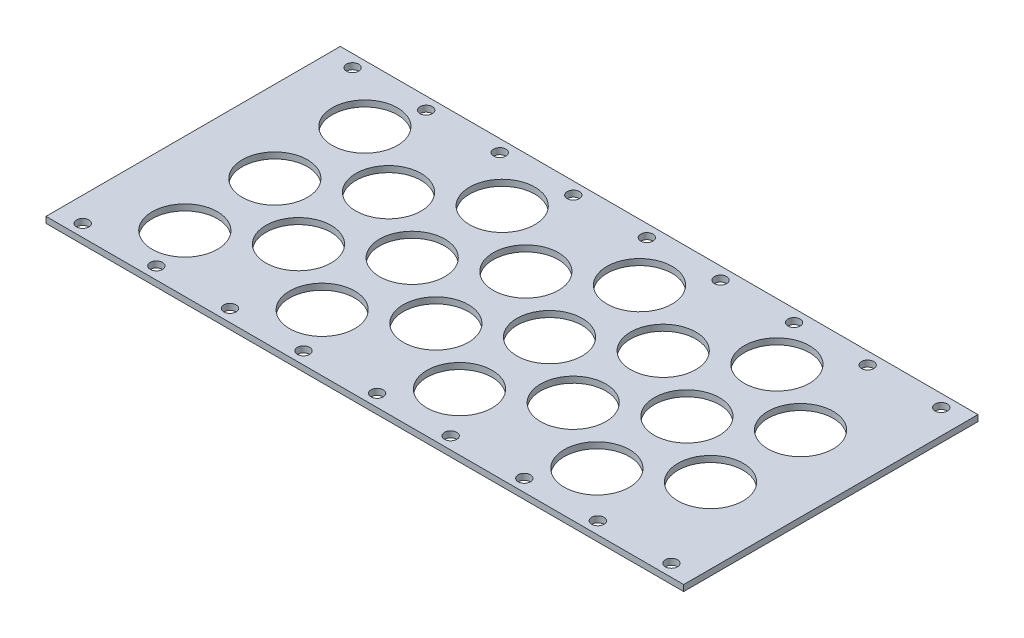
from build123d import *

# Parameters (mm, degrees)
SKETCH1_W           = 330.2
SKETCH1_H           = 152.4
BOSS_EXTRUDE1_DEPTH = 3.175
SKETCH2_R           = 3.175
CUT_EXTRUDE1_DEPTH  = 4.175
SKETCH3_R           = 16.891
CUT_EXTRUDE2_DEPTH  = 4.175


with BuildPart() as part:
    # Sketch1 → Boss-Extrude1 (new body)
    with BuildSketch(Plane(origin=(0, 0, 0), x_dir=(1, 0, 0), z_dir=(0, 1, 0))):
        Rectangle(SKETCH1_W, SKETCH1_H)
    extrude(amount=BOSS_EXTRUDE1_DEPTH)

    # Sketch2 → Cut-Extrude1 (cut, through all)
    with BuildSketch(Plane(origin=(0, 3.175, 0), x_dir=(1, 0, 0), z_dir=(0, 1, 0))):
        with Locations((-152.4, 69.85)):
            Circle(SKETCH2_R)
        with Locations((-114.3, 69.85)):
            Circle(SKETCH2_R)
        with Locations((-76.2, 69.85)):
            Circle(SKETCH2_R)
        with Locations((-38.1, 69.85)):
            Circle(SKETCH2_R)
        with Locations((0, 69.85)):
            Circle(SKETCH2_R)
        with Locations((38.1, 69.85)):
            Circle(SKETCH2_R)
        with Locations((76.2, 69.85)):
            Circle(SKETCH2_R)
        with Locations((114.3, 69.85)):
            Circle(SKETCH2_R)
        with Locations((152.4, 69.85)):
            Circle(SKETCH2_R)
        with Locations((-114.3, -69.85)):
            Circle(SKETCH2_R)
        with Locations((-76.2, -69.85)):
            Circle(SKETCH2_R)
        with Locations((-38.1, -69.85)):
            Circle(SKETCH2_R)
        with Locations((0, -69.85)):
            Circle(SKETCH2_R)
        with Locations((38.1, -69.85)):
            Circle(SKETCH2_R)
        with Locations((76.2, -69.85)):
            Circle(SKETCH2_R)
        with Locations((114.3, -69.85)):
            Circle(SKETCH2_R)
        with Locations((152.4, -69.85)):
            Circle(SKETCH2_R)
        with Locations((-152.4, -69.85)):
            Circle(SKETCH2_R)
    extrude(amount=-CUT_EXTRUDE1_DEPTH, mode=Mode.SUBTRACT)

    # Sketch3 → Cut-Extrude2 (cut, through all)
    with BuildSketch(Plane(origin=(0, 3.175, 0), x_dir=(1, 0, 0), z_dir=(0, 1, 0))):
        with Locations((-122.809, 46.609)):
            Circle(SKETCH3_R)
        with Locations((-122.809, 0)):
            Circle(SKETCH3_R)
        with Locations((-122.809, -46.609)):
            Circle(SKETCH3_R)
        with Locations((-87.249, 23.3045)):
            Circle(SKETCH3_R)
        with Locations((-87.249, -23.3045)):
            Circle(SKETCH3_R)
        with Locations((-51.689, 0)):
            Circle(SKETCH3_R)
        with Locations((-51.689, -46.609)):
            Circle(SKETCH3_R)
        with Locations((-16.129, -23.3045)):
            Circle(SKETCH3_R)
        with Locations((-51.689, 46.609)):
            Circle(SKETCH3_R)
        with Locations((-16.129, 23.3045)):
            Circle(SKETCH3_R)
        with Locations((19.431, 0)):
            Circle(SKETCH3_R)
        with Locations((19.431, -46.609)):
            Circle(SKETCH3_R)
        with Locations((54.991, -23.3045)):
            Circle(SKETCH3_R)
        with Locations((19.431, 46.609)):
            Circle(SKETCH3_R)
        with Locations((54.991, 23.3045)):
            Circle(SKETCH3_R)
        with Locations((90.551, 0)):
            Circle(SKETCH3_R)
        with Locations((90.551, -46.609)):
            Circle(SKETCH3_R)
        with Locations((126.111, -23.3045)):
            Circle(SKETCH3_R)
        with Locations((90.551, 46.609)):
            Circle(SKETCH3_R)
        with Locations((126.111, 23.3045)):
            Circle(SKETCH3_R)
    extrude(amount=-CUT_EXTRUDE2_DEPTH, mode=Mode.SUBTRACT)


solid = part.part
